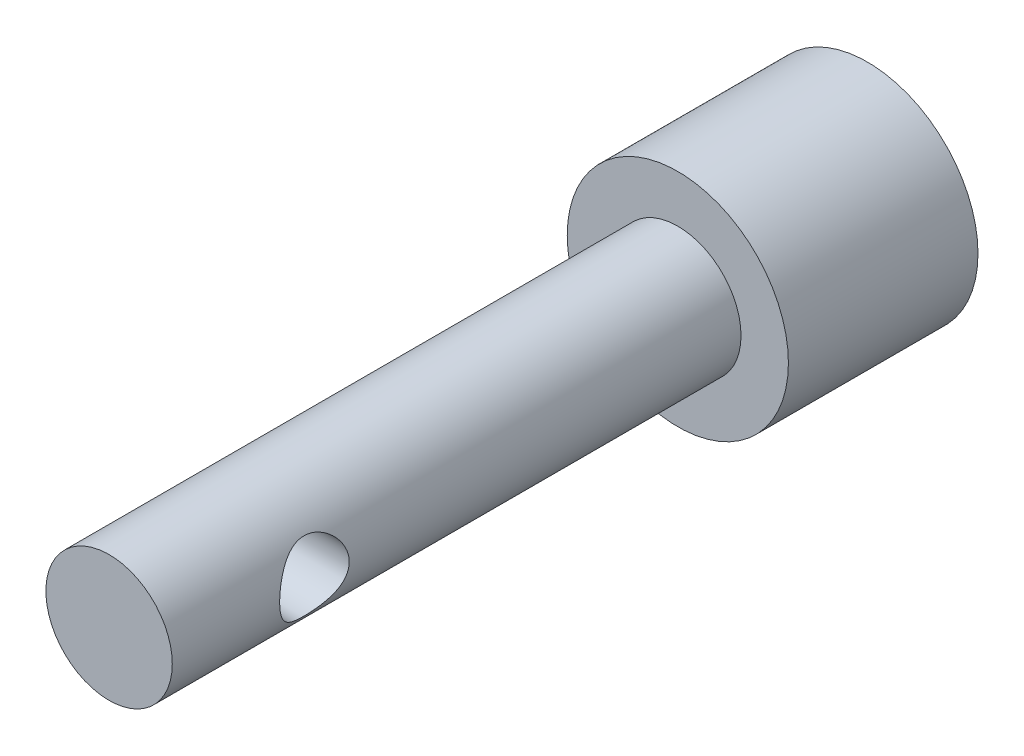
from build123d import *

# Parameters (mm, degrees)
SZKIC1_R                    = 3.5
DODANIE_WYCI_GNI_CIE1_DEPTH = 6
SZKIC2_R                    = 2
DODANIE_WYCI_GNI_CIE2_DEPTH = 18
SZKIC3_R                    = 1.1
WYTNIJ_WYCI_GNI_CIE1_DEPTH  = 6.5
SZKIC4_R                    = 2.3
WYTNIJ_WYCI_GNI_CIE2_DEPTH  = 3


with BuildPart() as part:
    # Szkic1 → Dodanie-wyciągnięcie1 (new body)
    with BuildSketch(Plane.XY):
        Circle(SZKIC1_R)
    extrude(amount=DODANIE_WYCI_GNI_CIE1_DEPTH)

    # Szkic2 → Dodanie-wyciągnięcie2 (add)
    with BuildSketch(Plane.XY.offset(6)):
        Circle(SZKIC2_R)
    extrude(amount=DODANIE_WYCI_GNI_CIE2_DEPTH)

    # Szkic3 → Wytnij-wyciągnięcie1 (cut, through all)
    with BuildSketch(Plane.ZY.offset(2)):
        with Locations((19.5, 0)):
            Circle(SZKIC3_R)
    extrude(amount=-WYTNIJ_WYCI_GNI_CIE1_DEPTH, mode=Mode.SUBTRACT)

    # Szkic4 → Wytnij-wyciągnięcie2 (cut)
    with BuildSketch(Plane(origin=(0, 0, 0), x_dir=(-1, 0, 0), z_dir=(0, 0, -1))):
        Circle(SZKIC4_R)
    extrude(amount=-WYTNIJ_WYCI_GNI_CIE2_DEPTH, mode=Mode.SUBTRACT)


solid = part.part
